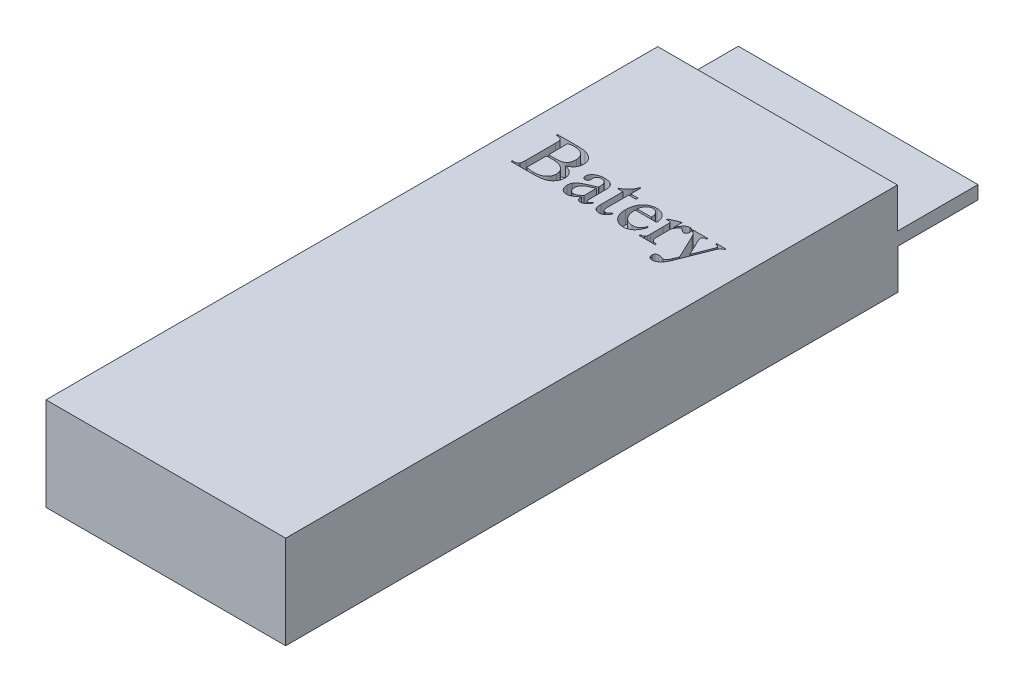
from build123d import *

# Parameters (mm, degrees)
CROQUIS1_W              = 18
CROQUIS1_H              = 52
SALIENTE_EXTRUIR1_DEPTH = 7
CROQUIS2_W              = 18
CROQUIS2_H              = 6.053678683
CORTAR_EXTRUIR1_DEPTH   = 3
CROQUIS3_W              = 18
CROQUIS3_H              = 6.01686178
CORTAR_EXTRUIR2_DEPTH   = 3
CORTAR_EXTRUIR3_DEPTH   = 1


with BuildPart() as part:
    # Croquis1 → Saliente-Extruir1 (new body)
    with BuildSketch(Plane(origin=(0, 0, 0), x_dir=(1, 0, 0), z_dir=(0, 1, 0))):
        Rectangle(CROQUIS1_W, CROQUIS1_H)
    extrude(amount=SALIENTE_EXTRUIR1_DEPTH)

    # Croquis2 → Cortar-Extruir1 (cut)
    with BuildSketch(Plane(origin=(0, 7, 0), x_dir=(1, 0, 0), z_dir=(0, 1, 0))):
        with Locations((0, 22.973160658)):
            Rectangle(CROQUIS2_W, CROQUIS2_H)
    extrude(amount=-CORTAR_EXTRUIR1_DEPTH, mode=Mode.SUBTRACT)

    # Croquis3 → Cortar-Extruir2 (cut)
    with BuildSketch(Plane.XZ):
        with Locations((0, -22.99156911)):
            Rectangle(CROQUIS3_W, CROQUIS3_H)
    extrude(amount=-CORTAR_EXTRUIR2_DEPTH, mode=Mode.SUBTRACT)

    # Croquis4 → Cortar-Extruir3 (cut)
    with BuildSketch(Plane(origin=(0, 7, 0), x_dir=(1, 0, 0), z_dir=(0, 1, 0))):
        with BuildLine():
            add(Edge.make_bspline(
                [(-4.724372974, 8.727557299), (-4.694929189, 8.721027832), (-4.637707809, 8.708338392), (-4.555525911, 8.684778611), (-4.479372452, 8.657959688), (-4.40840245, 8.62932506), (-4.343032497, 8.597591632), (-4.28351603, 8.56266264), (-4.229987641, 8.52462573), (-4.197797241, 8.496659089), (-4.182055265, 8.482982646)],
                knots=[0, 0, 0, 0, 9.0463e-05, 0.000175807, 0.000256279, 0.000332586, 0.000405281, 0.000474061, 0.0005394, 0.000601933, 0.000601933, 0.000601933, 0.000601933], degree=3))
            add(Edge.make_bspline(
                [(-4.182055265, 8.482982646), (-4.162136343, 8.463374427), (-4.122816716, 8.424668121), (-4.071991266, 8.360623359), (-4.02917853, 8.293314562), (-3.993792945, 8.222902004), (-3.966552308, 8.148968113), (-3.946568371, 8.071932676), (-3.93507859, 7.991650087), (-3.933648498, 7.937156341), (-3.932923321, 7.909523445)],
                knots=[0, 0, 0, 0, 8.3792e-05, 0.000165403, 0.00024463, 0.000322756, 0.000401343, 0.000480558, 0.000561121, 0.000643999, 0.000643999, 0.000643999, 0.000643999], degree=3))
            add(Edge.make_bspline(
                [(-3.932923321, 7.909523445), (-3.934689997, 7.867038948), (-3.938239613, 7.781678829), (-3.971661472, 7.655820935), (-4.022713132, 7.53233108), (-4.094288336, 7.414220677), (-4.1817646, 7.303814124), (-4.288515603, 7.209894897), (-4.409020164, 7.13080517), (-4.521594638, 7.078496542), (-4.621829509, 7.045812507), (-4.707126888, 7.024105225), (-4.801553606, 7.004665792), (-4.90574505, 6.991377394), (-5.018855342, 6.978605531), (-5.141536033, 6.970891072), (-5.273472226, 6.965201938), (-5.364665196, 6.964834663), (-5.411764467, 6.964644972)],
                knots=[0, 0, 0, 0, 0.000127228, 0.000255628, 0.000388082, 0.000527071, 0.000668587, 0.000808997, 0.000951619, 0.001099785, 0.001179769, 0.001267644, 0.001363723, 0.001468777, 0.0015826, 0.001705173, 0.001837441, 0.001978725, 0.001978725, 0.001978725, 0.001978725], degree=3))
            Line((-5.411764467, 6.964644972), (-7.044034432, 6.964644972))
            Line((-7.044034432, 6.964644972), (-7.044034432, 7.061867195))
            Line((-7.044034432, 7.061867195), (-6.917189814, 7.061867195))
            add(Edge.make_bspline(
                [(-6.917189814, 7.061867195), (-6.900194636, 7.062244787), (-6.86732365, 7.062975102), (-6.820099665, 7.070262004), (-6.776177138, 7.080232906), (-6.736621034, 7.096637712), (-6.700269647, 7.116526266), (-6.667420498, 7.14066318), (-6.638823023, 7.170225124), (-6.622963338, 7.192541786), (-6.614889467, 7.203902785)],
                knots=[0, 0, 0, 0, 5.0941e-05, 9.8526e-05, 0.000143107, 0.000185703, 0.0002265, 0.000267212, 0.000307497, 0.000349272, 0.000349272, 0.000349272, 0.000349272], degree=3))
            add(Edge.make_bspline(
                [(-6.614889467, 7.203902785), (-6.610058207, 7.212641937), (-6.599636597, 7.231493344), (-6.588874357, 7.265030448), (-6.578919457, 7.304291374), (-6.571731413, 7.350349701), (-6.565679276, 7.402797284), (-6.561359765, 7.461842947), (-6.558085193, 7.527181002), (-6.557978836, 7.572785425), (-6.557923321, 7.596589417)],
                knots=[0, 0, 0, 0, 2.9894e-05, 6.4485e-05, 0.000105197, 0.000151398, 0.000204158, 0.000263578, 0.00032897, 0.000400371, 0.000400371, 0.000400371, 0.000400371], degree=3))
            Line((-6.557923321, 7.596589417), (-6.557923321, 9.832700528))
            add(Edge.make_bspline(
                [(-6.557923321, 9.832700528), (-6.557885022, 9.859040795), (-6.55781206, 9.909221164), (-6.56223184, 9.980605589), (-6.566677976, 10.044601811), (-6.575407469, 10.100791732), (-6.584894268, 10.149623449), (-6.596425097, 10.190940924), (-6.611676845, 10.224360296), (-6.624276798, 10.242744089), (-6.630080439, 10.251211813)],
                knots=[0, 0, 0, 0, 7.8997e-05, 0.000150495, 0.000214518, 0.000271343, 0.000320946, 0.000363725, 0.000399745, 0.000430505, 0.000430505, 0.000430505, 0.000430505], degree=3))
            add(Edge.make_bspline(
                [(-6.630080439, 10.251211813), (-6.647222239, 10.269209398), (-6.681811593, 10.305525586), (-6.750635075, 10.341923648), (-6.830313318, 10.363389832), (-6.887161811, 10.366028812), (-6.917189814, 10.36742275)],
                knots=[0, 0, 0, 0, 7.4148e-05, 0.000149619, 0.000229959, 0.000319907, 0.000319907, 0.000319907, 0.000319907], degree=3))
            Line((-6.917189814, 10.36742275), (-7.044034432, 10.36742275))
            Line((-7.044034432, 10.36742275), (-7.044034432, 10.464644972))
            Line((-7.044034432, 10.464644972), (-5.566712383, 10.464644972))
            add(Edge.make_bspline(
                [(-5.566712383, 10.464644972), (-5.50110964, 10.46410693), (-5.376867082, 10.463087951), (-5.200727366, 10.450508922), (-5.044655081, 10.432412525), (-4.948570472, 10.411421219), (-4.903626446, 10.401602438)],
                knots=[0, 0, 0, 0, 0.00019676, 0.000372636, 0.000529591, 0.000667528, 0.000667528, 0.000667528, 0.000667528], degree=3))
            add(Edge.make_bspline(
                [(-4.903626446, 10.401602438), (-4.87286201, 10.393424964), (-4.812756572, 10.377448378), (-4.726545058, 10.346700133), (-4.645795172, 10.311804333), (-4.570401263, 10.272552508), (-4.501165401, 10.228063484), (-4.436604909, 10.180243459), (-4.378138305, 10.127026684), (-4.3258054, 10.069285425), (-4.279652447, 10.008175254), (-4.237893088, 9.94532433), (-4.204260937, 9.87898056), (-4.175428789, 9.811203042), (-4.154659435, 9.740703688), (-4.138189319, 9.668517106), (-4.129133799, 9.593674168), (-4.127961035, 9.5430814), (-4.127367765, 9.517487854)],
                knots=[0, 0, 0, 0, 9.5465e-05, 0.000186512, 0.000274279, 0.000359216, 0.00044118, 0.000520933, 0.000599974, 0.000677941, 0.000754354, 0.000829565, 0.000903962, 0.000977171, 0.001050214, 0.001124113, 0.001199104, 0.001275879, 0.001275879, 0.001275879, 0.001275879], degree=3))
            add(Edge.make_bspline(
                [(-4.127367765, 9.517487854), (-4.128920647, 9.47402088), (-4.131980903, 9.388360716), (-4.162242803, 9.264064956), (-4.209983864, 9.146794484), (-4.264633163, 9.055530817), (-4.318296658, 8.988380158), (-4.36221395, 8.939834926), (-4.411850068, 8.896225798), (-4.46549936, 8.855330028), (-4.524030038, 8.818625834), (-4.586392709, 8.784047705), (-4.653589499, 8.753697057), (-4.700462273, 8.736387325), (-4.724372974, 8.727557299)],
                knots=[0, 0, 0, 0, 0.000130202, 0.000256589, 0.000381275, 0.000509062, 0.000573949, 0.000638992, 0.00070516, 0.000771849, 0.000841172, 0.000912217, 0.000985638, 0.001062093, 0.001062093, 0.001062093, 0.001062093], degree=3))
        make_face()
        with BuildLine():
            add(Edge.make_bspline(
                [(-6.07181221, 8.849844625), (-6.037944315, 8.843871325), (-5.965957188, 8.831174914), (-5.850500476, 8.81970474), (-5.722248897, 8.813057628), (-5.632549273, 8.81227562), (-5.585701099, 8.811867195)],
                knots=[0, 0, 0, 0, 0.000103142, 0.000219231, 0.000347777, 0.000488312, 0.000488312, 0.000488312, 0.000488312], degree=3))
            add(Edge.make_bspline(
                [(-5.585701099, 8.811867195), (-5.55531712, 8.812220599), (-5.496550458, 8.812904129), (-5.411389363, 8.816383651), (-5.332141133, 8.823532894), (-5.258763949, 8.831982533), (-5.191221817, 8.844693159), (-5.129316726, 8.858296117), (-5.073388783, 8.876186442), (-5.007802492, 8.90161616), (-4.935432946, 8.940921748), (-4.863380816, 9.001568673), (-4.807756728, 9.074246734), (-4.769423029, 9.157773599), (-4.744665593, 9.248316682), (-4.724154388, 9.342534953), (-4.712884016, 9.441006146), (-4.711436459, 9.507841144), (-4.710701099, 9.54179341)],
                knots=[0, 0, 0, 0, 9.1158e-05, 0.000176313, 0.000255601, 0.000329839, 0.000397775, 0.000461708, 0.000519842, 0.000573722, 0.000672653, 0.000765336, 0.000854207, 0.000944924, 0.001039139, 0.001135371, 0.001234013, 0.001335863, 0.001335863, 0.001335863, 0.001335863], degree=3))
            add(Edge.make_bspline(
                [(-4.710701099, 9.54179341), (-4.711499926, 9.568152264), (-4.713073452, 9.620073822), (-4.723474915, 9.696628384), (-4.743082935, 9.769942583), (-4.768615293, 9.840550781), (-4.80167857, 9.908458966), (-4.842733828, 9.972693867), (-4.891327364, 10.034017695), (-4.946229281, 10.09228205), (-5.008552893, 10.145707028), (-5.078234949, 10.192172315), (-5.154343838, 10.231758671), (-5.237457527, 10.263744383), (-5.32697444, 10.2887153), (-5.423635886, 10.305884575), (-5.526720971, 10.316607456), (-5.597826548, 10.31806417), (-5.63431221, 10.318811639)],
                knots=[0, 0, 0, 0, 7.9084e-05, 0.00015578, 0.000231129, 0.000306339, 0.000380732, 0.000457221, 0.000534564, 0.000615155, 0.000697046, 0.000780257, 0.000865867, 0.000953883, 0.001046949, 0.001144233, 0.001248078, 0.001357519, 0.001357519, 0.001357519, 0.001357519], degree=3))
            add(Edge.make_bspline(
                [(-5.63431221, 10.318811639), (-5.673830568, 10.318033749), (-5.750988742, 10.316514946), (-5.863788456, 10.306101539), (-5.970472237, 10.287315052), (-6.038513161, 10.268684561), (-6.07181221, 10.259566847)],
                knots=[0, 0, 0, 0, 0.00011855, 0.000231465, 0.000339484, 0.000443017, 0.000443017, 0.000443017, 0.000443017], degree=3))
            Line((-6.07181221, 10.259566847), (-6.07181221, 8.849844625))
        make_face(mode=Mode.SUBTRACT)
        with BuildLine():
            add(Edge.make_bspline(
                [(-6.07181221, 7.181116327), (-6.022054532, 7.170101833), (-5.923058016, 7.148187698), (-5.773798948, 7.1268048), (-5.625449473, 7.113273643), (-5.526991703, 7.111409045), (-5.477845196, 7.110478306)],
                knots=[0, 0, 0, 0, 0.000152837, 0.000304081, 0.000451998, 0.000599421, 0.000599421, 0.000599421, 0.000599421], degree=3))
            add(Edge.make_bspline(
                [(-5.477845196, 7.110478306), (-5.439834037, 7.110860798), (-5.366181522, 7.111601936), (-5.259184594, 7.123050141), (-5.158972814, 7.138924693), (-5.065877118, 7.162873145), (-4.979246703, 7.191955083), (-4.900264342, 7.229383858), (-4.827910395, 7.273064682), (-4.762619112, 7.322953602), (-4.705497629, 7.378569367), (-4.654386866, 7.436459029), (-4.61191415, 7.498324321), (-4.576406289, 7.56300775), (-4.549948336, 7.631630207), (-4.529964545, 7.702744331), (-4.518359773, 7.777488968), (-4.516966896, 7.828212136), (-4.516256654, 7.854076396)],
                knots=[0, 0, 0, 0, 0.000113973, 0.00022084, 0.000322483, 0.000418093, 0.00050889, 0.000596212, 0.00067971, 0.00076205, 0.000842092, 0.000918546, 0.000993342, 0.001066751, 0.00113939, 0.001213469, 0.001288021, 0.001365588, 0.001365588, 0.001365588, 0.001365588], degree=3))
            add(Edge.make_bspline(
                [(-4.516256654, 7.854076396), (-4.517877506, 7.888347253), (-4.521125743, 7.957027082), (-4.542634086, 8.059217594), (-4.581029727, 8.158278179), (-4.631565022, 8.255354014), (-4.698074425, 8.347083551), (-4.783396464, 8.427953263), (-4.884165434, 8.499512947), (-5.001944589, 8.558757433), (-5.134544275, 8.607568647), (-5.28242772, 8.642134384), (-5.444868149, 8.662451769), (-5.558042978, 8.664809112), (-5.616842592, 8.666033861)],
                knots=[0, 0, 0, 0, 0.00010282, 0.000206054, 0.000311577, 0.00042064, 0.000533668, 0.000649697, 0.000771722, 0.000903186, 0.001044004, 0.001194703, 0.001357781, 0.001534129, 0.001534129, 0.001534129, 0.001534129], degree=3))
            add(Edge.make_bspline(
                [(-5.616842592, 8.666033861), (-5.642415904, 8.666188354), (-5.691795507, 8.666486665), (-5.762926598, 8.664426304), (-5.828270592, 8.663307376), (-5.90373642, 8.660180003), (-5.984624155, 8.656247924), (-6.045022215, 8.646715867), (-6.07181221, 8.642487854)],
                knots=[0, 0, 0, 0, 7.6714e-05, 0.000148128, 0.000213467, 0.000272756, 0.000374764, 0.000456079, 0.000456079, 0.000456079, 0.000456079], degree=3))
            Line((-6.07181221, 8.642487854), (-6.07181221, 7.181116327))
        make_face(mode=Mode.SUBTRACT)
        with BuildLine():
            add(Edge.make_bspline(
                [(-2.085701099, 7.302644104), (-2.114494036, 7.280524248), (-2.169107381, 7.238568148), (-2.247599109, 7.180511666), (-2.31653191, 7.128169988), (-2.377914487, 7.084608738), (-2.430613298, 7.047555728), (-2.475035689, 7.018359602), (-2.510598307, 6.995564608), (-2.532245107, 6.984521675), (-2.541430265, 6.979835945)],
                knots=[0, 0, 0, 0, 0.000108923, 0.000206601, 0.000292886, 0.000368556, 0.000432398, 0.000486117, 0.000528065, 0.000558983, 0.000558983, 0.000558983, 0.000558983], degree=3))
            add(Edge.make_bspline(
                [(-2.541430265, 6.979835945), (-2.564764862, 6.969863073), (-2.611286848, 6.949980243), (-2.684734076, 6.931009563), (-2.75995828, 6.917864851), (-2.811010538, 6.916649871), (-2.836894675, 6.916033861)],
                knots=[0, 0, 0, 0, 7.6023e-05, 0.000151567, 0.000226988, 0.000304555, 0.000304555, 0.000304555, 0.000304555], degree=3))
            add(Edge.make_bspline(
                [(-2.836894675, 6.916033861), (-2.856915733, 6.916729268), (-2.8960878, 6.918089861), (-2.953711208, 6.925494676), (-3.008436209, 6.939238615), (-3.060195647, 6.958451675), (-3.109683718, 6.981984738), (-3.155981757, 7.012047716), (-3.200206651, 7.046917543), (-3.241072772, 7.087255085), (-3.278166459, 7.131659141), (-3.310040361, 7.180022157), (-3.33815685, 7.231260504), (-3.359373537, 7.286696381), (-3.377538167, 7.344902907), (-3.389078311, 7.406601743), (-3.397226432, 7.471552103), (-3.397870751, 7.51604955), (-3.398201099, 7.538863722)],
                knots=[0, 0, 0, 0, 6.0081e-05, 0.000117551, 0.000173922, 0.000228951, 0.000282965, 0.000337957, 0.000394185, 0.000451655, 0.000509908, 0.000567418, 0.000625189, 0.000684851, 0.000745162, 0.000807874, 0.000872881, 0.000941279, 0.000941279, 0.000941279, 0.000941279], degree=3))
            add(Edge.make_bspline(
                [(-3.398201099, 7.538863722), (-3.397567192, 7.567570171), (-3.39633451, 7.62339213), (-3.379842512, 7.7034413), (-3.35766709, 7.778724871), (-3.332954488, 7.823545117), (-3.32072714, 7.845721361)],
                knots=[0, 0, 0, 0, 8.595e-05, 0.000167136, 0.000244484, 0.000320233, 0.000320233, 0.000320233, 0.000320233], degree=3))
            add(Edge.make_bspline(
                [(-3.32072714, 7.845721361), (-3.300846076, 7.875780614), (-3.259089036, 7.938915333), (-3.174909076, 8.024041401), (-3.072901773, 8.107219626), (-2.973152239, 8.172728418), (-2.881256936, 8.226427874), (-2.799140642, 8.268239929), (-2.706686458, 8.313238348), (-2.604020159, 8.361263594), (-2.489267535, 8.409398984), (-2.364492725, 8.460904069), (-2.229043018, 8.515283608), (-2.134644513, 8.550534749), (-2.085701099, 8.568811639)],
                knots=[0, 0, 0, 0, 0.000107899, 0.000226624, 0.000357236, 0.000502381, 0.000584063, 0.000676466, 0.000778715, 0.000892559, 0.001016428, 0.00115198, 0.001297538, 0.001454266, 0.001454266, 0.001454266, 0.001454266], degree=3))
            Line((-2.085701099, 8.568811639), (-2.085701099, 8.657678827))
            add(Edge.make_bspline(
                [(-2.085701099, 8.657678827), (-2.085930398, 8.684775389), (-2.086372346, 8.737000805), (-2.091455766, 8.812119183), (-2.101040617, 8.880426835), (-2.111413337, 8.942484207), (-2.127733228, 8.997218038), (-2.146475354, 9.045814919), (-2.169137857, 9.087747728), (-2.203595984, 9.134551326), (-2.256468644, 9.181656673), (-2.332466438, 9.222036724), (-2.421284871, 9.24582949), (-2.484565094, 9.248146966), (-2.517884258, 9.249367195)],
                knots=[0, 0, 0, 0, 8.1286e-05, 0.000156669, 0.000225633, 0.000288203, 0.000345169, 0.00039665, 0.000444236, 0.000487683, 0.000570505, 0.000654101, 0.000743833, 0.000843624, 0.000843624, 0.000843624, 0.000843624], degree=3))
            add(Edge.make_bspline(
                [(-2.517884258, 9.249367195), (-2.543328069, 9.248553049), (-2.592041515, 9.246994327), (-2.660785612, 9.22942841), (-2.722385845, 9.20299457), (-2.755894742, 9.175504687), (-2.772333043, 9.162019104)],
                knots=[0, 0, 0, 0, 7.6141e-05, 0.000145775, 0.000211716, 0.000275215, 0.000275215, 0.000275215, 0.000275215], degree=3))
            add(Edge.make_bspline(
                [(-2.772333043, 9.162019104), (-2.787230047, 9.147676571), (-2.81569626, 9.120269879), (-2.845842265, 9.070603155), (-2.865405685, 9.018127664), (-2.867663977, 8.981415577), (-2.868795717, 8.963017368)],
                knots=[0, 0, 0, 0, 6.1785e-05, 0.000118064, 0.000172836, 0.00022786, 0.00022786, 0.00022786, 0.00022786], degree=3))
            Line((-2.868795717, 8.963017368), (-2.863478876, 8.814145841))
            add(Edge.make_bspline(
                [(-2.863478876, 8.814145841), (-2.864104161, 8.795589923), (-2.86529118, 8.760364014), (-2.876986234, 8.710732322), (-2.895536358, 8.667344569), (-2.923033123, 8.631840671), (-2.955684859, 8.603287665), (-2.994227548, 8.583181391), (-3.037389402, 8.570581398), (-3.067960039, 8.56941435), (-3.083747974, 8.568811639)],
                knots=[0, 0, 0, 0, 5.5577e-05, 0.000105505, 0.000152086, 0.000195989, 0.000239076, 0.000281209, 0.000325446, 0.000372691, 0.000372691, 0.000372691, 0.000372691], degree=3))
            add(Edge.make_bspline(
                [(-3.083747974, 8.568811639), (-3.099069598, 8.569306856), (-3.128797934, 8.570267719), (-3.170466084, 8.584522333), (-3.209046674, 8.603906234), (-3.241435638, 8.633470021), (-3.268741851, 8.669492027), (-3.287362319, 8.712775731), (-3.299128303, 8.761621638), (-3.300342913, 8.796095509), (-3.300978876, 8.814145841)],
                knots=[0, 0, 0, 0, 4.5731e-05, 8.8731e-05, 0.000130864, 0.00017445, 0.00021896, 0.000265541, 0.00031473, 0.000368791, 0.000368791, 0.000368791, 0.000368791], degree=3))
            add(Edge.make_bspline(
                [(-3.300978876, 8.814145841), (-3.300216284, 8.832178665), (-3.298699348, 8.868049262), (-3.287409306, 8.921090036), (-3.270189563, 8.973140664), (-3.244403213, 9.023565259), (-3.212235804, 9.073097347), (-3.173417646, 9.122033388), (-3.126648613, 9.168863272), (-3.073652394, 9.214520747), (-3.014064145, 9.256755217), (-2.948557048, 9.294180646), (-2.876950428, 9.325473723), (-2.799893133, 9.35103551), (-2.716759682, 9.37078589), (-2.628183495, 9.385114364), (-2.533737165, 9.393352831), (-2.469035885, 9.394574156), (-2.435853008, 9.395200528)],
                knots=[0, 0, 0, 0, 5.4062e-05, 0.000107538, 0.000162062, 0.000218109, 0.00027689, 0.000339048, 0.000405111, 0.000475138, 0.000548689, 0.000623868, 0.000701066, 0.000782731, 0.000867106, 0.000957137, 0.001051691, 0.001151239, 0.001151239, 0.001151239, 0.001151239], degree=3))
            add(Edge.make_bspline(
                [(-2.435853008, 9.395200528), (-2.385644728, 9.393948519), (-2.289366421, 9.391547693), (-2.152290241, 9.371828947), (-2.02846489, 9.339729537), (-1.954887934, 9.304915007), (-1.919359953, 9.288104174)],
                knots=[0, 0, 0, 0, 0.000150546, 0.000288684, 0.000414723, 0.000532411, 0.000532411, 0.000532411, 0.000532411], degree=3))
            add(Edge.make_bspline(
                [(-1.919359953, 9.288104174), (-1.894941221, 9.273517895), (-1.846318612, 9.244473679), (-1.78402326, 9.185206044), (-1.732418114, 9.114433275), (-1.707346679, 9.060975664), (-1.694533564, 9.033655389)],
                knots=[0, 0, 0, 0, 8.5114e-05, 0.000169478, 0.000255923, 0.000346281, 0.000346281, 0.000346281, 0.000346281], degree=3))
            add(Edge.make_bspline(
                [(-1.694533564, 9.033655389), (-1.690854413, 9.023065845), (-1.682801456, 8.999887362), (-1.672717597, 8.960641754), (-1.666100023, 8.913724581), (-1.658652176, 8.859893192), (-1.654840791, 8.798469153), (-1.650763539, 8.729882092), (-1.648609398, 8.653640662), (-1.648341433, 8.600460329), (-1.648201099, 8.572609382)],
                knots=[0, 0, 0, 0, 3.3627e-05, 7.3602e-05, 0.000121303, 0.000175662, 0.000236597, 0.00030582, 0.000381809, 0.000465363, 0.000465363, 0.000465363, 0.000465363], degree=3))
            Line((-1.648201099, 8.572609382), (-1.648201099, 7.757613722))
            add(Edge.make_bspline(
                [(-1.648201099, 7.757613722), (-1.648289477, 7.730269356), (-1.648456419, 7.678617567), (-1.647348881, 7.605199471), (-1.647032701, 7.540370438), (-1.645127667, 7.483672269), (-1.644081468, 7.435281146), (-1.641491914, 7.395048616), (-1.639656596, 7.363080857), (-1.635852299, 7.332791838), (-1.629242589, 7.30358253), (-1.62068264, 7.274222932), (-1.609301206, 7.251133066), (-1.592761922, 7.228632622), (-1.56473725, 7.212210879), (-1.540783744, 7.209191797), (-1.528951967, 7.207700528)],
                knots=[0, 0, 0, 0, 8.2031e-05, 0.000154952, 0.000220277, 0.000276505, 0.000325139, 0.00036546, 0.000397442, 0.000421183, 0.000456939, 0.000487207, 0.000512683, 0.0005338, 0.000570274, 0.000605876, 0.000605876, 0.000605876, 0.000605876], degree=3))
            add(Edge.make_bspline(
                [(-1.528951967, 7.207700528), (-1.516355957, 7.208452691), (-1.492292125, 7.209889647), (-1.470309194, 7.219723969), (-1.459833043, 7.224410597)],
                knots=[0, 0, 0, 0, 3.7496e-05, 7.1633e-05, 7.1633e-05, 7.1633e-05, 7.1633e-05], degree=3))
            add(Edge.make_bspline(
                [(-1.459833043, 7.224410597), (-1.449047484, 7.23181191), (-1.422259988, 7.25019414), (-1.37961175, 7.289282433), (-1.322461311, 7.339869355), (-1.281885803, 7.379883619), (-1.25931221, 7.402144972)],
                knots=[0, 0, 0, 0, 3.9203e-05, 9.7367e-05, 0.000173189, 0.000268266, 0.000268266, 0.000268266, 0.000268266], degree=3))
            Line((-1.25931221, 7.402144972), (-1.25931221, 7.266185771))
            add(Edge.make_bspline(
                [(-1.25931221, 7.266185771), (-1.282762476, 7.238531838), (-1.327870011, 7.185338382), (-1.398417034, 7.11368257), (-1.468581427, 7.053279503), (-1.537560418, 7.00321894), (-1.606290965, 6.964961718), (-1.673931064, 6.936947499), (-1.741209934, 6.919081519), (-1.786336853, 6.917036622), (-1.808465856, 6.916033861)],
                knots=[0, 0, 0, 0, 0.000108751, 0.000209187, 0.000301293, 0.000386233, 0.000464433, 0.00053665, 0.000605548, 0.000671842, 0.000671842, 0.000671842, 0.000671842], degree=3))
            add(Edge.make_bspline(
                [(-1.808465856, 6.916033861), (-1.828607267, 6.916871727), (-1.86738315, 6.91848477), (-1.922079349, 6.936123488), (-1.970208358, 6.963854926), (-2.012183158, 7.003234733), (-2.045637406, 7.057113015), (-2.067756458, 7.126097629), (-2.083317965, 7.209299595), (-2.084864968, 7.269893862), (-2.085701099, 7.302644104)],
                knots=[0, 0, 0, 0, 6.0239e-05, 0.000115972, 0.000170427, 0.00022577, 0.000286879, 0.000358462, 0.000441888, 0.000540014, 0.000540014, 0.000540014, 0.000540014], degree=3))
        make_face()
        with BuildLine():
            Line((-2.085701099, 7.478099834), (-2.085701099, 8.422978306))
            add(Edge.make_bspline(
                [(-2.085701099, 8.422978306), (-2.116578822, 8.409788615), (-2.175307602, 8.384702099), (-2.259424721, 8.349216043), (-2.334427678, 8.315599867), (-2.401156949, 8.285520036), (-2.459082501, 8.258041057), (-2.508478525, 8.233776915), (-2.549624648, 8.212717232), (-2.573875238, 8.198980607), (-2.584724536, 8.192835077)],
                knots=[0, 0, 0, 0, 0.000100731, 0.000191589, 0.000273876, 0.000347297, 0.000411172, 0.000466201, 0.000512403, 0.000549806, 0.000549806, 0.000549806, 0.000549806], degree=3))
            add(Edge.make_bspline(
                [(-2.584724536, 8.192835077), (-2.616549405, 8.173468651), (-2.676907858, 8.136738649), (-2.756505069, 8.07447581), (-2.822829913, 8.011797408), (-2.87451168, 7.946420127), (-2.913898764, 7.878983187), (-2.939896397, 7.808397014), (-2.958081353, 7.735233472), (-2.959819849, 7.68506337), (-2.960701099, 7.659631952)],
                knots=[0, 0, 0, 0, 0.000111674, 0.000211799, 0.000302581, 0.000384787, 0.000461004, 0.000535768, 0.000609835, 0.000685976, 0.000685976, 0.000685976, 0.000685976], degree=3))
            add(Edge.make_bspline(
                [(-2.960701099, 7.659631952), (-2.959512563, 7.628365161), (-2.957223115, 7.568136678), (-2.936005228, 7.481592398), (-2.901017784, 7.403540047), (-2.853119708, 7.335406052), (-2.796890261, 7.279290764), (-2.734645445, 7.23775596), (-2.667280681, 7.212815945), (-2.620872237, 7.209407192), (-2.597636863, 7.207700528)],
                knots=[0, 0, 0, 0, 9.3674e-05, 0.000180442, 0.000265431, 0.000348874, 0.000428901, 0.000502424, 0.00057186, 0.000641482, 0.000641482, 0.000641482, 0.000641482], degree=3))
            add(Edge.make_bspline(
                [(-2.597636863, 7.207700528), (-2.580615457, 7.208762252), (-2.545177804, 7.210972706), (-2.490206596, 7.223903239), (-2.431889128, 7.245665939), (-2.369598243, 7.275386006), (-2.304038276, 7.31419147), (-2.234006668, 7.36041672), (-2.160771237, 7.416158923), (-2.111382125, 7.456910234), (-2.085701099, 7.478099834)],
                knots=[0, 0, 0, 0, 5.1093e-05, 0.000106374, 0.000168606, 0.000237574, 0.000313133, 0.000396976, 0.000489186, 0.000589069, 0.000589069, 0.000589069, 0.000589069], degree=3))
        make_face(mode=Mode.SUBTRACT)
        with BuildLine():
            Line((-0.432923321, 10.124367195), (-0.432923321, 9.346589417))
            Line((-0.432923321, 9.346589417), (0.115470776, 9.346589417))
            Line((0.115470776, 9.346589417), (0.115470776, 9.200756084))
            Line((0.115470776, 9.200756084), (-0.432923321, 9.200756084))
            Line((-0.432923321, 9.200756084), (-0.432923321, 7.611780389))
            add(Edge.make_bspline(
                [(-0.432923321, 7.611780389), (-0.432036188, 7.575293548), (-0.430409982, 7.508409437), (-0.419473258, 7.417330428), (-0.399196367, 7.345262072), (-0.369712626, 7.290632559), (-0.331462154, 7.253322963), (-0.289655681, 7.22648576), (-0.24259024, 7.210724193), (-0.209731427, 7.208724485), (-0.19290596, 7.207700528)],
                knots=[0, 0, 0, 0, 0.00010947, 0.00020067, 0.00027444, 0.000332945, 0.000384504, 0.000432973, 0.000481011, 0.000531422, 0.000531422, 0.000531422, 0.000531422], degree=3))
            add(Edge.make_bspline(
                [(-0.19290596, 7.207700528), (-0.17842933, 7.20828045), (-0.149690484, 7.209431704), (-0.106847923, 7.218953324), (-0.065310315, 7.235346388), (-0.024147233, 7.256333152), (0.014602181, 7.283508059), (0.049183895, 7.317196103), (0.078157472, 7.357441345), (0.093792216, 7.387005115), (0.101798901, 7.402144972)],
                knots=[0, 0, 0, 0, 4.3401e-05, 8.6159e-05, 0.000130875, 0.000177077, 0.000224492, 0.000272296, 0.000321214, 0.000372561, 0.000372561, 0.000372561, 0.000372561], degree=3))
            Line((0.101798901, 7.402144972), (0.199021124, 7.402144972))
            add(Edge.make_bspline(
                [(0.199021124, 7.402144972), (0.183008659, 7.363959872), (0.152086286, 7.290218949), (0.091636302, 7.190459957), (0.021412024, 7.105385787), (-0.058646691, 7.037399116), (-0.143189039, 6.984174152), (-0.229466244, 6.944442265), (-0.318217723, 6.920508384), (-0.378098186, 6.917519372), (-0.407858217, 6.916033861)],
                knots=[0, 0, 0, 0, 0.000124088, 0.000239632, 0.000348552, 0.000453593, 0.000553267, 0.000647433, 0.000737704, 0.000826895, 0.000826895, 0.000826895, 0.000826895], degree=3))
            add(Edge.make_bspline(
                [(-0.407858217, 6.916033861), (-0.427912955, 6.917041595), (-0.468122822, 6.919062107), (-0.528332294, 6.931521248), (-0.587656344, 6.953210873), (-0.645518473, 6.982403581), (-0.699707154, 7.019128302), (-0.74658848, 7.06488593), (-0.78633648, 7.117460708), (-0.818792531, 7.179044372), (-0.842096282, 7.253334512), (-0.859168459, 7.342460206), (-0.868175799, 7.448804992), (-0.869637847, 7.52517715), (-0.870423321, 7.566207472)],
                knots=[0, 0, 0, 0, 6.0177e-05, 0.000120656, 0.000183602, 0.000249161, 0.000314685, 0.000379144, 0.000444769, 0.0005117, 0.00058688, 0.000677448, 0.000783486, 0.000906591, 0.000906591, 0.000906591, 0.000906591], degree=3))
            Line((-0.870423321, 7.566207472), (-0.870423321, 9.200756084))
            Line((-0.870423321, 9.200756084), (-1.25931221, 9.200756084))
            Line((-1.25931221, 9.200756084), (-1.25931221, 9.269875007))
            add(Edge.make_bspline(
                [(-1.25931221, 9.269875007), (-1.234053479, 9.28007774), (-1.182212218, 9.301017925), (-1.105817052, 9.341827716), (-1.029196429, 9.392393094), (-0.952052829, 9.451541275), (-0.875873586, 9.518496175), (-0.802695392, 9.593539007), (-0.73246188, 9.675629915), (-0.689500434, 9.734912929), (-0.667623842, 9.765100702)],
                knots=[0, 0, 0, 0, 8.1682e-05, 0.000167646, 0.000259287, 0.000356817, 0.000459066, 0.000563266, 0.000671025, 0.000782831, 0.000782831, 0.000782831, 0.000782831], degree=3))
            add(Edge.make_bspline(
                [(-0.667623842, 9.765100702), (-0.655244238, 9.784716567), (-0.626715458, 9.829921303), (-0.584484588, 9.910118774), (-0.533797132, 10.009756497), (-0.499960087, 10.083960228), (-0.481534432, 10.124367195)],
                knots=[0, 0, 0, 0, 6.9564e-05, 0.00016031, 0.000271726, 0.000404933, 0.000404933, 0.000404933, 0.000404933], degree=3))
            Line((-0.481534432, 10.124367195), (-0.432923321, 10.124367195))
        make_face()
        with BuildLine():
            add(Edge.make_bspline(
                [(0.782354457, 8.471589417), (0.782642521, 8.429019986), (0.78320281, 8.346221667), (0.796052677, 8.225684881), (0.815437788, 8.112412746), (0.842554205, 8.005665018), (0.879086326, 7.906330098), (0.923353823, 7.813652586), (0.975340686, 7.727730068), (1.0174315, 7.676636214), (1.038322339, 7.651276917)],
                knots=[0, 0, 0, 0, 0.00012764, 0.000248263, 0.000363146, 0.000472206, 0.000578176, 0.000680095, 0.000780012, 0.000878472, 0.000878472, 0.000878472, 0.000878472], degree=3))
            add(Edge.make_bspline(
                [(1.038322339, 7.651276917), (1.059896529, 7.627531995), (1.10187479, 7.581330003), (1.171339013, 7.520789311), (1.243053247, 7.468911065), (1.318134246, 7.427028741), (1.39550232, 7.393352413), (1.476439311, 7.371418555), (1.559785992, 7.355774832), (1.616517225, 7.354286428), (1.645201679, 7.353533861)],
                knots=[0, 0, 0, 0, 9.6175e-05, 0.000187134, 0.000275871, 0.000361229, 0.000444606, 0.000528281, 0.00061232, 0.00069827, 0.00069827, 0.00069827, 0.00069827], degree=3))
            add(Edge.make_bspline(
                [(1.645201679, 7.353533861), (1.682780625, 7.354743069), (1.755997926, 7.357099041), (1.861714966, 7.378444117), (1.960417466, 7.411460409), (2.036140814, 7.452141585), (2.093315853, 7.492029022), (2.133391464, 7.530013002), (2.172468864, 7.573549072), (2.209462198, 7.623720028), (2.244510849, 7.680488845), (2.277786291, 7.743760763), (2.309756125, 7.813397314), (2.328341071, 7.862813091), (2.337910012, 7.888256084)],
                knots=[0, 0, 0, 0, 0.000112621, 0.000219426, 0.000322232, 0.000423833, 0.000476104, 0.000530928, 0.000589023, 0.000651458, 0.000717639, 0.000788992, 0.000865808, 0.000947335, 0.000947335, 0.000947335, 0.000947335], degree=3))
            Line((2.337910012, 7.888256084), (2.386521124, 7.839644972))
            add(Edge.make_bspline(
                [(2.386521124, 7.839644972), (2.381399804, 7.808919611), (2.371248727, 7.748018223), (2.348237646, 7.65883671), (2.318831778, 7.572847252), (2.281747825, 7.490377982), (2.239278033, 7.410604178), (2.190852328, 7.333484405), (2.134554913, 7.260558607), (2.073980995, 7.190287882), (2.007830416, 7.125568638), (1.935599157, 7.07030558), (1.860818066, 7.021593845), (1.780490536, 6.983835129), (1.697060747, 6.952943649), (1.608808236, 6.931970958), (1.516735201, 6.918700338), (1.453841828, 6.916932073), (1.421894387, 6.916033861)],
                knots=[0, 0, 0, 0, 9.3412e-05, 0.000185154, 0.000275951, 0.000365719, 0.000456106, 0.000546925, 0.000638529, 0.000732203, 0.000825132, 0.000915531, 0.001004661, 0.001092309, 0.001181212, 0.001271112, 0.00136392, 0.001459731, 0.001459731, 0.001459731, 0.001459731], degree=3))
            add(Edge.make_bspline(
                [(1.421894387, 6.916033861), (1.387155494, 6.917096748), (1.318607637, 6.919194069), (1.217682954, 6.934621137), (1.120746867, 6.960640548), (1.027564118, 6.996546731), (0.938027938, 7.042355037), (0.852520338, 7.099011098), (0.771279402, 7.166407786), (0.693869231, 7.242612402), (0.623563992, 7.328115517), (0.561866437, 7.421318833), (0.508834001, 7.520983875), (0.467509222, 7.628669197), (0.433654554, 7.742574596), (0.410743642, 7.863980443), (0.395660253, 7.992185732), (0.394209706, 8.080122981), (0.393465568, 8.12523525)],
                knots=[0, 0, 0, 0, 0.000104194, 0.000205599, 0.000305458, 0.000404762, 0.000504633, 0.000606594, 0.000711821, 0.00082085, 0.000932009, 0.001043238, 0.001155697, 0.001269946, 0.001388679, 0.001511721, 0.001640138, 0.001775415, 0.001775415, 0.001775415, 0.001775415], degree=3))
            add(Edge.make_bspline(
                [(0.393465568, 8.12523525), (0.394113464, 8.173899631), (0.395375554, 8.268697025), (0.411718144, 8.406385385), (0.434038431, 8.536318944), (0.468827446, 8.657362897), (0.511736408, 8.771019398), (0.566004456, 8.875490412), (0.628527662, 8.972860031), (0.701684245, 9.060066484), (0.780758925, 9.139307439), (0.866660038, 9.207047032), (0.956785055, 9.265362058), (1.051800616, 9.313537597), (1.152320937, 9.350246494), (1.257598913, 9.375628117), (1.367687212, 9.392371484), (1.442845688, 9.39424564), (1.481139179, 9.395200528)],
                knots=[0, 0, 0, 0, 0.000145905, 0.00028422, 0.000415472, 0.000540984, 0.000661446, 0.000779323, 0.000893508, 0.001007875, 0.001120127, 0.001228784, 0.001335392, 0.001441713, 0.001547683, 0.001655635, 0.001766167, 0.001880982, 0.001880982, 0.001880982, 0.001880982], degree=3))
            add(Edge.make_bspline(
                [(1.481139179, 9.395200528), (1.513590925, 9.394589245), (1.576963165, 9.393395521), (1.669703199, 9.380586142), (1.757986002, 9.361133925), (1.84196182, 9.333686578), (1.921730632, 9.298543938), (1.996878639, 9.255296328), (2.067536878, 9.203709322), (2.133001937, 9.144760265), (2.193104428, 9.079851566), (2.245372853, 9.008648022), (2.288368385, 8.931521794), (2.324380255, 8.849681799), (2.352713441, 8.762722101), (2.37199068, 8.670253985), (2.384700627, 8.572709966), (2.385905024, 8.505811049), (2.386521124, 8.471589417)],
                knots=[0, 0, 0, 0, 9.7296e-05, 0.000190002, 0.000280295, 0.000368206, 0.000454582, 0.00054135, 0.000627795, 0.000716545, 0.000805243, 0.00089275, 0.000980838, 0.001069604, 0.001160639, 0.001254643, 0.001352621, 0.001455231, 0.001455231, 0.001455231, 0.001455231], degree=3))
            Line((2.386521124, 8.471589417), (0.782354457, 8.471589417))
        make_face()
        with BuildLine():
            Line((0.782354457, 8.61742275), (1.851798901, 8.61742275))
            add(Edge.make_bspline(
                [(1.851798901, 8.61742275), (1.849352191, 8.652648492), (1.844835634, 8.717674193), (1.833883026, 8.806511099), (1.819699242, 8.879010219), (1.805111914, 8.920345704), (1.798630499, 8.938711813)],
                knots=[0, 0, 0, 0, 0.000105907, 0.000195502, 0.000268498, 0.000326864, 0.000326864, 0.000326864, 0.000326864], degree=3))
            add(Edge.make_bspline(
                [(1.798630499, 8.938711813), (1.787254103, 8.961773823), (1.76484416, 9.007202825), (1.722538947, 9.069874621), (1.669493433, 9.122175339), (1.611623123, 9.167756677), (1.548942049, 9.204092217), (1.483985276, 9.230190371), (1.417346836, 9.246199046), (1.372356549, 9.248307267), (1.349737269, 9.249367195)],
                knots=[0, 0, 0, 0, 7.7119e-05, 0.000151915, 0.000225497, 0.000299641, 0.000372467, 0.000442002, 0.000509066, 0.000576875, 0.000576875, 0.000576875, 0.000576875], degree=3))
            add(Edge.make_bspline(
                [(1.349737269, 9.249367195), (1.315579804, 9.247289713), (1.247588181, 9.243154414), (1.148875664, 9.210514626), (1.057211336, 9.156032599), (0.986364491, 9.096560599), (0.935785975, 9.038570478), (0.900596179, 8.990756405), (0.870093224, 8.938450282), (0.843544583, 8.882339616), (0.82131552, 8.821861963), (0.804339952, 8.757161092), (0.790206846, 8.688754746), (0.785008624, 8.641533506), (0.782354457, 8.61742275)],
                knots=[0, 0, 0, 0, 0.000102333, 0.000203698, 0.00030818, 0.000420801, 0.000479463, 0.000538713, 0.000598635, 0.000660812, 0.000724731, 0.000791615, 0.000861328, 0.000934058, 0.000934058, 0.000934058, 0.000934058], degree=3))
        make_face(mode=Mode.SUBTRACT)
        with BuildLine():
            Line((3.358743346, 9.395200528), (3.358743346, 8.806550354))
            add(Edge.make_bspline(
                [(3.358743346, 8.806550354), (3.382702148, 8.852958672), (3.428100304, 8.940895122), (3.501884751, 9.060964773), (3.576132414, 9.162521244), (3.650439044, 9.246570901), (3.725942951, 9.312430103), (3.80249249, 9.360101334), (3.880760928, 9.389560039), (3.933750633, 9.393353736), (3.959546297, 9.395200528)],
                knots=[0, 0, 0, 0, 0.000156646, 0.000296819, 0.000422301, 0.000533634, 0.000632742, 0.000721713, 0.000803155, 0.000880409, 0.000880409, 0.000880409, 0.000880409], degree=3))
            add(Edge.make_bspline(
                [(3.959546297, 9.395200528), (3.981936681, 9.394033997), (4.02541951, 9.391768556), (4.08792608, 9.374032878), (4.143532079, 9.342729827), (4.191610874, 9.30081216), (4.231925068, 9.251981364), (4.26124683, 9.19757444), (4.278723712, 9.138763152), (4.281127965, 9.098333679), (4.282354457, 9.077709209)],
                knots=[0, 0, 0, 0, 6.7116e-05, 0.000130341, 0.000192901, 0.000256997, 0.000320699, 0.000381865, 0.000441232, 0.000503055, 0.000503055, 0.000503055, 0.000503055], degree=3))
            add(Edge.make_bspline(
                [(4.282354457, 9.077709209), (4.281655937, 9.059679296), (4.280302742, 9.024751162), (4.268941645, 8.974381656), (4.248436868, 8.929082461), (4.222620749, 8.888340226), (4.190776378, 8.854878986), (4.155437043, 8.829704188), (4.116199334, 8.814223352), (4.088803053, 8.812656668), (4.074997686, 8.811867195)],
                knots=[0, 0, 0, 0, 5.4062e-05, 0.00010473, 0.000153701, 0.000202579, 0.00024878, 0.000291342, 0.000331969, 0.000373237, 0.000373237, 0.000373237, 0.000373237], degree=3))
            add(Edge.make_bspline(
                [(4.074997686, 8.811867195), (4.060405947, 8.813197788), (4.028960033, 8.816065281), (3.981168322, 8.836595483), (3.929329312, 8.86711168), (3.877780518, 8.908805198), (3.827821401, 8.949594228), (3.7818855, 8.98086282), (3.742837759, 9.001089098), (3.71789575, 9.004762386), (3.707376158, 9.006311639)],
                knots=[0, 0, 0, 0, 4.3719e-05, 9.4216e-05, 0.000154138, 0.000224021, 0.000292704, 0.000347476, 0.000390977, 0.000422705, 0.000422705, 0.000422705, 0.000422705], degree=3))
            add(Edge.make_bspline(
                [(3.707376158, 9.006311639), (3.699178026, 9.0057324), (3.68196338, 9.004516098), (3.656290626, 8.993322546), (3.62955056, 8.976571091), (3.612952629, 8.961305762), (3.604077547, 8.953143236)],
                knots=[0, 0, 0, 0, 2.4495e-05, 5.1435e-05, 8.2834e-05, 0.000118919, 0.000118919, 0.000118919, 0.000118919], degree=3))
            add(Edge.make_bspline(
                [(3.604077547, 8.953143236), (3.583584901, 8.932563112), (3.539484641, 8.8882746), (3.479183002, 8.80687289), (3.417898415, 8.708505001), (3.379286622, 8.635667754), (3.358743346, 8.596914938)],
                knots=[0, 0, 0, 0, 8.7034e-05, 0.000187297, 0.000302993, 0.000434535, 0.000434535, 0.000434535, 0.000434535], degree=3))
            Line((3.358743346, 8.596914938), (3.358743346, 7.499367195))
            add(Edge.make_bspline(
                [(3.358743346, 7.499367195), (3.359140375, 7.469698291), (3.359886128, 7.413970187), (3.370104675, 7.336252853), (3.384495171, 7.268942881), (3.402164484, 7.23026784), (3.410392651, 7.21225782)],
                knots=[0, 0, 0, 0, 8.8919e-05, 0.00016702, 0.000234998, 0.000294243, 0.000294243, 0.000294243, 0.000294243], degree=3))
            add(Edge.make_bspline(
                [(3.410392651, 7.21225782), (3.417083287, 7.201323923), (3.430803877, 7.17890161), (3.459911791, 7.149969611), (3.495327508, 7.124095839), (3.537684121, 7.100927351), (3.588741673, 7.082363115), (3.64956524, 7.071527258), (3.719512051, 7.062387547), (3.769619682, 7.062047743), (3.796243346, 7.061867195)],
                knots=[0, 0, 0, 0, 3.834e-05, 7.8625e-05, 0.000122072, 0.000169658, 0.000223, 0.000284222, 0.000354598, 0.000434384, 0.000434384, 0.000434384, 0.000434384], degree=3))
            Line((3.796243346, 7.061867195), (3.796243346, 6.964644972))
            Line((3.796243346, 6.964644972), (2.580965568, 6.964644972))
            Line((2.580965568, 6.964644972), (2.580965568, 7.061867195))
            add(Edge.make_bspline(
                [(2.580965568, 7.061867195), (2.606848437, 7.062524178), (2.655315331, 7.063754409), (2.722561943, 7.07448442), (2.780457996, 7.090531748), (2.812178614, 7.109796094), (2.827059318, 7.118833341)],
                knots=[0, 0, 0, 0, 7.7567e-05, 0.000145248, 0.000204107, 0.000256118, 0.000256118, 0.000256118, 0.000256118], degree=3))
            add(Edge.make_bspline(
                [(2.827059318, 7.118833341), (2.83654386, 7.126307186), (2.85585149, 7.141521652), (2.878585655, 7.172240904), (2.897150665, 7.208418262), (2.904990209, 7.235375901), (2.909090568, 7.249475702)],
                knots=[0, 0, 0, 0, 3.6085e-05, 7.3457e-05, 0.000113541, 0.000157496, 0.000157496, 0.000157496, 0.000157496], degree=3))
            add(Edge.make_bspline(
                [(2.909090568, 7.249475702), (2.911048357, 7.260086133), (2.916187071, 7.287935899), (2.918612868, 7.340613242), (2.921032685, 7.413251982), (2.921167766, 7.468470996), (2.921243346, 7.499367195)],
                knots=[0, 0, 0, 0, 3.2341e-05, 8.4887e-05, 0.00015784, 0.000250508, 0.000250508, 0.000250508, 0.000250508], degree=3))
            Line((2.921243346, 7.499367195), (2.921243346, 8.422978306))
            add(Edge.make_bspline(
                [(2.921243346, 8.422978306), (2.921298734, 8.454626231), (2.921403308, 8.514378655), (2.920712985, 8.59894721), (2.919095919, 8.673380783), (2.917409508, 8.737679557), (2.916584226, 8.791921036), (2.913198325, 8.835945616), (2.910323917, 8.870147279), (2.906706609, 8.901771824), (2.89974538, 8.932439987), (2.887400273, 8.962867562), (2.873038783, 8.989072275), (2.849070208, 9.015781161), (2.810756671, 9.04023698), (2.775813589, 9.043420345), (2.757940394, 9.045048618)],
                knots=[0, 0, 0, 0, 9.4944e-05, 0.000179257, 0.000253708, 0.000318288, 0.000372237, 0.000416395, 0.00045071, 0.000475205, 0.000511868, 0.00054459, 0.000573513, 0.000600952, 0.000651756, 0.000704952, 0.000704952, 0.000704952, 0.000704952], degree=3))
            add(Edge.make_bspline(
                [(2.757940394, 9.045048618), (2.733367044, 9.042868565), (2.679752435, 9.038112084), (2.6299622, 9.017484772), (2.602992478, 9.006311639)],
                knots=[0, 0, 0, 0, 7.3582e-05, 0.000160543, 0.000160543, 0.000160543, 0.000160543], degree=3))
            Line((2.602992478, 9.006311639), (2.580965568, 9.103533861))
            Line((2.580965568, 9.103533861), (3.256204283, 9.395200528))
            Line((3.256204283, 9.395200528), (3.358743346, 9.395200528))
        make_face()
        with BuildLine():
            Line((4.236021992, 9.346589417), (5.357115742, 9.346589417))
            Line((5.357115742, 9.346589417), (5.357115742, 9.249367195))
            Line((5.357115742, 9.249367195), (5.30318779, 9.249367195))
            add(Edge.make_bspline(
                [(5.30318779, 9.249367195), (5.285181238, 9.248824352), (5.251184201, 9.247799445), (5.203450403, 9.239222535), (5.163182893, 9.222923214), (5.129884168, 9.201769444), (5.104310403, 9.175581363), (5.08659935, 9.146063001), (5.075113126, 9.113718187), (5.073749037, 9.090974265), (5.073044561, 9.079228306)],
                knots=[0, 0, 0, 0, 5.4013e-05, 0.000101979, 0.000144575, 0.00018355, 0.000219538, 0.000253276, 0.000286183, 0.000321328, 0.000321328, 0.000321328, 0.000321328], degree=3))
            add(Edge.make_bspline(
                [(5.073044561, 9.079228306), (5.074249324, 9.061161605), (5.076899841, 9.02141427), (5.094792271, 8.958279556), (5.120468589, 8.885406008), (5.14441566, 8.83519751), (5.157354457, 8.808069452)],
                knots=[0, 0, 0, 0, 5.4189e-05, 0.000119218, 0.000195858, 0.000285937, 0.000285937, 0.000285937, 0.000285937], degree=3))
            Line((5.157354457, 8.808069452), (5.717141783, 7.634566847))
            Line((5.717141783, 7.634566847), (6.226798901, 8.918963549))
            add(Edge.make_bspline(
                [(6.226798901, 8.918963549), (6.239520591, 8.952503391), (6.2643316, 9.017915876), (6.268205561, 9.087740529), (6.270093172, 9.121763028)],
                knots=[0, 0, 0, 0, 0.000106891, 0.00020847, 0.00020847, 0.00020847, 0.00020847], degree=3))
            add(Edge.make_bspline(
                [(6.270093172, 9.121763028), (6.269702935, 9.135244345), (6.269009138, 9.159212615), (6.257610747, 9.180186187), (6.252623554, 9.189362854)],
                knots=[0, 0, 0, 0, 3.9759e-05, 7.0686e-05, 7.0686e-05, 7.0686e-05, 7.0686e-05], degree=3))
            add(Edge.make_bspline(
                [(6.252623554, 9.189362854), (6.244177254, 9.198016987), (6.22577468, 9.216872381), (6.193120988, 9.231632263), (6.159933513, 9.241584557), (6.125403261, 9.246271534), (6.082797063, 9.249227842), (6.05160505, 9.24931809), (6.034633103, 9.249367195)],
                knots=[0, 0, 0, 0, 3.6021e-05, 7.8481e-05, 0.000105399, 0.00013999, 0.000182633, 0.000233528, 0.000233528, 0.000233528, 0.000233528], degree=3))
            Line((6.034633103, 9.249367195), (6.034633103, 9.346589417))
            Line((6.034633103, 9.346589417), (6.721265047, 9.346589417))
            Line((6.721265047, 9.346589417), (6.721265047, 9.249367195))
            add(Edge.make_bspline(
                [(6.721265047, 9.249367195), (6.706282558, 9.247632628), (6.677871001, 9.244343339), (6.638442441, 9.235269476), (6.604408656, 9.223700906), (6.574211347, 9.210125395), (6.546984225, 9.190226472), (6.519676757, 9.164843051), (6.491045152, 9.132797808), (6.472238386, 9.108716576), (6.462258971, 9.095938375)],
                knots=[0, 0, 0, 0, 4.5223e-05, 8.5758e-05, 0.000121067, 0.000153004, 0.000184614, 0.000221708, 0.000264728, 0.000313363, 0.000313363, 0.000313363, 0.000313363], degree=3))
            add(Edge.make_bspline(
                [(6.462258971, 9.095938375), (6.457313318, 9.087654812), (6.444756698, 9.066623505), (6.426522989, 9.025519064), (6.402238396, 8.969577194), (6.38469794, 8.926852278), (6.374910881, 8.903013028)],
                knots=[0, 0, 0, 0, 2.8923e-05, 7.3433e-05, 0.000134669, 0.000211968, 0.000211968, 0.000211968, 0.000211968], degree=3))
            Line((6.374910881, 8.903013028), (5.464212096, 6.611454868))
            add(Edge.make_bspline(
                [(5.464212096, 6.611454868), (5.452666413, 6.580675731), (5.43009375, 6.520500243), (5.391072817, 6.434747916), (5.34998757, 6.354655578), (5.3067004, 6.279917172), (5.260861273, 6.210689222), (5.210869506, 6.148320623), (5.159292214, 6.090794552), (5.104789909, 6.039703635), (5.049781183, 5.994193524), (4.994466363, 5.95520239), (4.940418057, 5.92172264), (4.886230492, 5.894627924), (4.832861458, 5.873484661), (4.779782986, 5.85792137), (4.72728707, 5.848424594), (4.692294467, 5.847195454), (4.675041089, 5.846589417)],
                knots=[0, 0, 0, 0, 9.8595e-05, 0.000192761, 0.000282442, 0.000368553, 0.000451764, 0.000531242, 0.000608136, 0.000683358, 0.000755131, 0.000822148, 0.000886239, 0.000945683, 0.001003653, 0.001058219, 0.001111414, 0.001163153, 0.001163153, 0.001163153, 0.001163153], degree=3))
            add(Edge.make_bspline(
                [(4.675041089, 5.846589417), (4.650835517, 5.847595763), (4.604204945, 5.849534428), (4.537948418, 5.869127531), (4.477302342, 5.898201396), (4.426549788, 5.941647753), (4.383764711, 5.990680615), (4.353763151, 6.046051933), (4.334349084, 6.104565583), (4.332096687, 6.145195904), (4.330965568, 6.165599834)],
                knots=[0, 0, 0, 0, 7.2413e-05, 0.000139498, 0.000205736, 0.000272645, 0.000338389, 0.000399917, 0.000460453, 0.00052152, 0.00052152, 0.00052152, 0.00052152], degree=3))
            add(Edge.make_bspline(
                [(4.330965568, 6.165599834), (4.33168339, 6.184696794), (4.333065631, 6.221469939), (4.348097239, 6.273401437), (4.371902562, 6.319355739), (4.405284181, 6.35853135), (4.446571468, 6.391024267), (4.496090125, 6.413554498), (4.552225055, 6.427743704), (4.591903758, 6.429172043), (4.612758103, 6.42992275)],
                knots=[0, 0, 0, 0, 5.7148e-05, 0.000110045, 0.000160667, 0.000211335, 0.000263297, 0.000316983, 0.000373354, 0.000435803, 0.000435803, 0.000435803, 0.000435803], degree=3))
            add(Edge.make_bspline(
                [(4.612758103, 6.42992275), (4.629253602, 6.42900436), (4.66530289, 6.426997309), (4.723044218, 6.415632622), (4.788583663, 6.396962231), (4.834380319, 6.380821752), (4.858851853, 6.372197056)],
                knots=[0, 0, 0, 0, 4.9517e-05, 0.000108213, 0.000176031, 0.000253854, 0.000253854, 0.000253854, 0.000253854], degree=3))
            add(Edge.make_bspline(
                [(4.858851853, 6.372197056), (4.875242502, 6.366152467), (4.904566544, 6.355338266), (4.943835474, 6.34395029), (4.97215394, 6.334824408), (4.987942799, 6.333293021), (4.994051506, 6.332700528)],
                knots=[0, 0, 0, 0, 5.237e-05, 9.3694e-05, 0.000122806, 0.000141177, 0.000141177, 0.000141177, 0.000141177], degree=3))
            add(Edge.make_bspline(
                [(4.994051506, 6.332700528), (5.007561274, 6.333958539), (5.036014965, 6.336608108), (5.079191814, 6.351654566), (5.122420634, 6.378250239), (5.169825204, 6.412410606), (5.21645398, 6.463900819), (5.263249317, 6.532077701), (5.309069956, 6.618967363), (5.337320436, 6.683657849), (5.35255845, 6.718551222)],
                knots=[0, 0, 0, 0, 4.0606e-05, 8.5522e-05, 0.000135548, 0.000192515, 0.000260221, 0.000342607, 0.000440143, 0.000554361, 0.000554361, 0.000554361, 0.000554361], degree=3))
            Line((5.35255845, 6.718551222), (5.499151332, 7.08617275))
            Line((5.499151332, 7.08617275), (4.653773728, 8.860478306))
            add(Edge.make_bspline(
                [(4.653773728, 8.860478306), (4.646588396, 8.874490517), (4.631059342, 8.90477393), (4.602645148, 8.95135274), (4.569344332, 9.003288397), (4.544063828, 9.038581943), (4.530726853, 9.057201396)],
                knots=[0, 0, 0, 0, 4.7227e-05, 0.000102067, 0.000163586, 0.000232282, 0.000232282, 0.000232282, 0.000232282], degree=3))
            add(Edge.make_bspline(
                [(4.530726853, 9.057201396), (4.520685014, 9.070938241), (4.502031837, 9.096455064), (4.474964726, 9.130873315), (4.450254689, 9.157830791), (4.433385447, 9.171785167), (4.425909144, 9.177969625)],
                knots=[0, 0, 0, 0, 5.1043e-05, 9.4814e-05, 0.000131351, 0.000160433, 0.000160433, 0.000160433, 0.000160433], degree=3))
            add(Edge.make_bspline(
                [(4.425909144, 9.177969625), (4.414640048, 9.184778794), (4.390073191, 9.199622917), (4.34690161, 9.218664152), (4.294382638, 9.234544943), (4.256317009, 9.244212731), (4.236021992, 9.249367195)],
                knots=[0, 0, 0, 0, 3.9475e-05, 8.6055e-05, 0.000141064, 0.000203886, 0.000203886, 0.000203886, 0.000203886], degree=3))
            Line((4.236021992, 9.249367195), (4.236021992, 9.346589417))
        make_face()
    extrude(amount=-CORTAR_EXTRUIR3_DEPTH, mode=Mode.SUBTRACT)


solid = part.part
